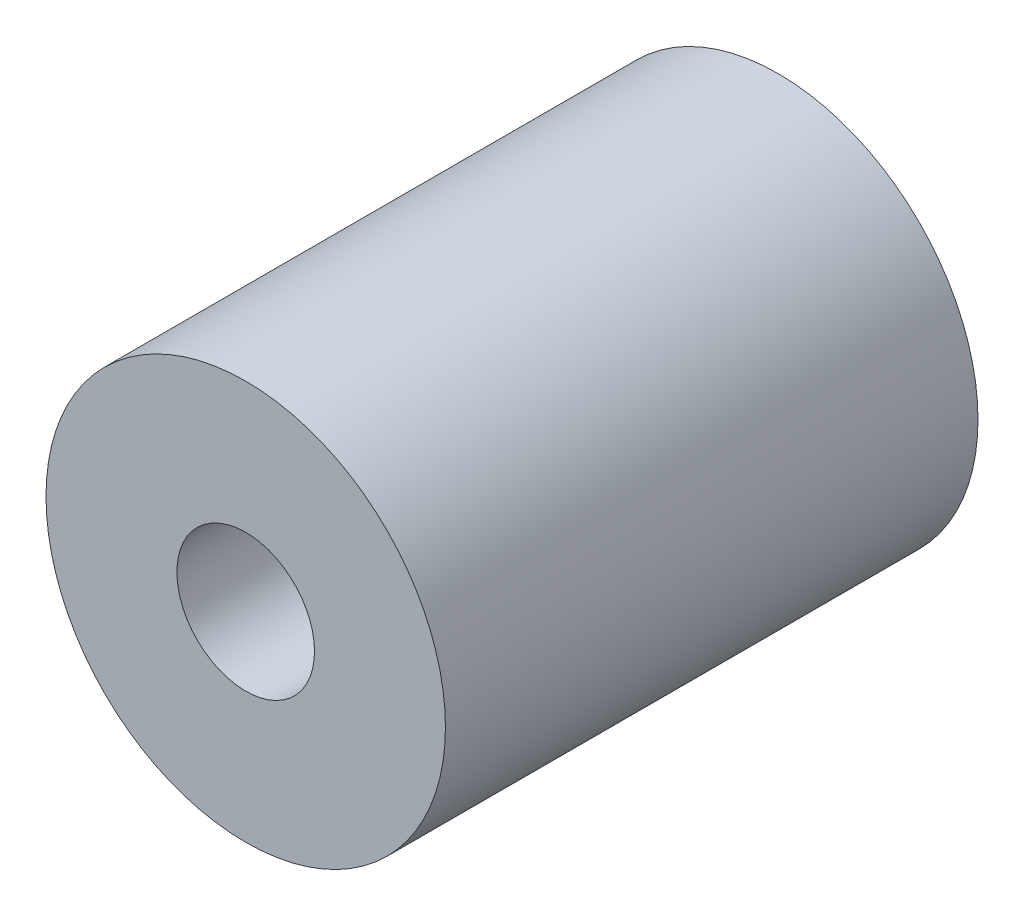
from build123d import *

# Parameters (mm, degrees)
SKETCH1_R           = 9
SKETCH1_R_2         = 3.1
BOSS_EXTRUDE1_DEPTH = 24


with BuildPart() as part:
    # Sketch1 → Boss-Extrude1 (new body)
    with BuildSketch(Plane.XY):
        Circle(SKETCH1_R)
        Circle(SKETCH1_R_2, mode=Mode.SUBTRACT)
    extrude(amount=BOSS_EXTRUDE1_DEPTH)


solid = part.part
